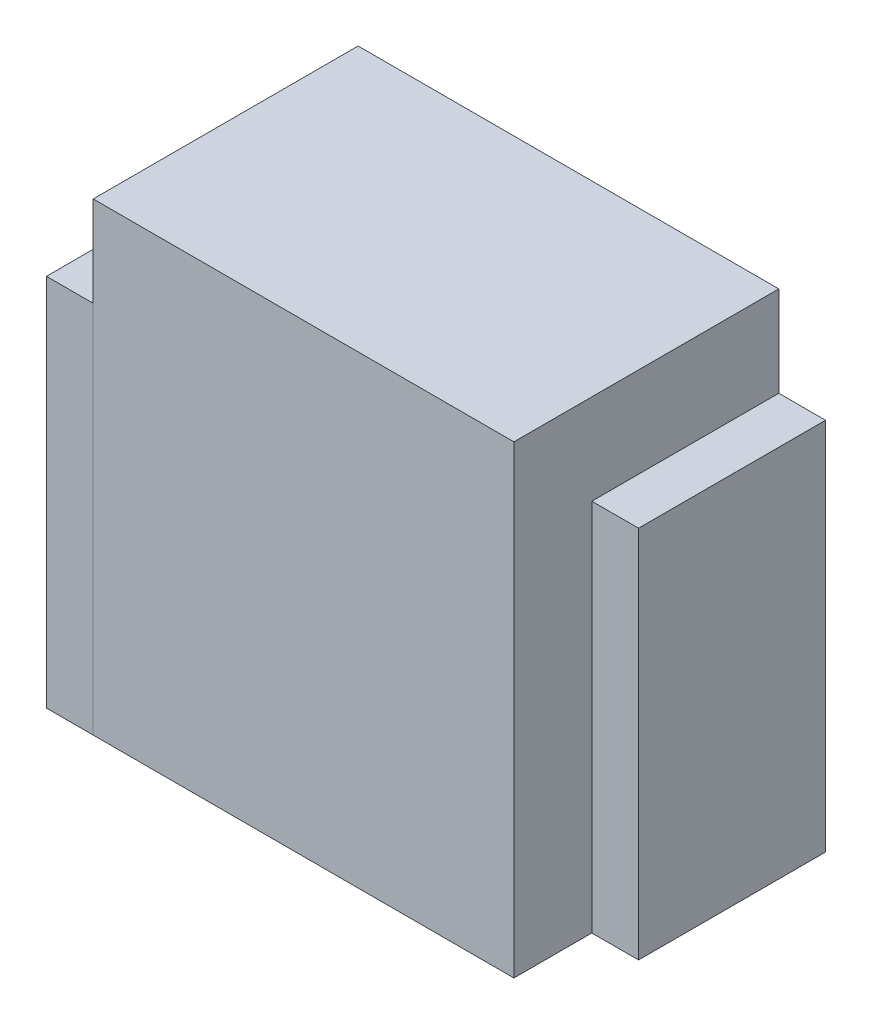
from build123d import *

# Parameters (mm, degrees)
SKETCH1_W             = 270
SKETCH1_H             = 170
BOSS_EXTRUDE1_DEPTH   = 298
SKETCH2_W             = 120
SKETCH2_H             = 240
BOSS_EXTRUDE2_DEPTH   = 30
SKETCH2_W_2           = 45
BOSS_EXTRUDE2_2_DEPTH = 30
SKETCH3_W             = 120
SKETCH3_H             = 240
BOSS_EXTRUDE3_DEPTH   = 30


with BuildPart() as part:
    # Sketch1 → Boss-Extrude1 (new body)
    with BuildSketch(Plane(origin=(0, 0, 0), x_dir=(1, 0, 0), z_dir=(0, 1, 0))):
        with Locations((135, 85)):
            Rectangle(SKETCH1_W, SKETCH1_H)
    extrude(amount=BOSS_EXTRUDE1_DEPTH)


with BuildPart() as body_2:
    # Sketch2 → Boss-Extrude2 (new body)
    with BuildSketch(Plane.ZY):
        with Locations((-110, 120)):
            Rectangle(SKETCH2_W, SKETCH2_H)
    extrude(amount=BOSS_EXTRUDE2_DEPTH)


with BuildPart() as body_3:
    # Sketch2 → Boss-Extrude2 2 (new body)
    with BuildSketch(Plane.ZY):
        with Locations((-22.5, 120)):
            Rectangle(SKETCH2_W_2, SKETCH2_H)
    extrude(amount=BOSS_EXTRUDE2_2_DEPTH)


with BuildPart() as body_4:
    # Sketch3 → Boss-Extrude3 (new body)
    with BuildSketch(Plane(origin=(270, 0, 0), x_dir=(0, 0, -1), z_dir=(1, 0, 0))):
        with Locations((110, 120)):
            Rectangle(SKETCH3_W, SKETCH3_H)
    extrude(amount=BOSS_EXTRUDE3_DEPTH)


solid = Compound([part.part, body_2.part, body_3.part, body_4.part])
